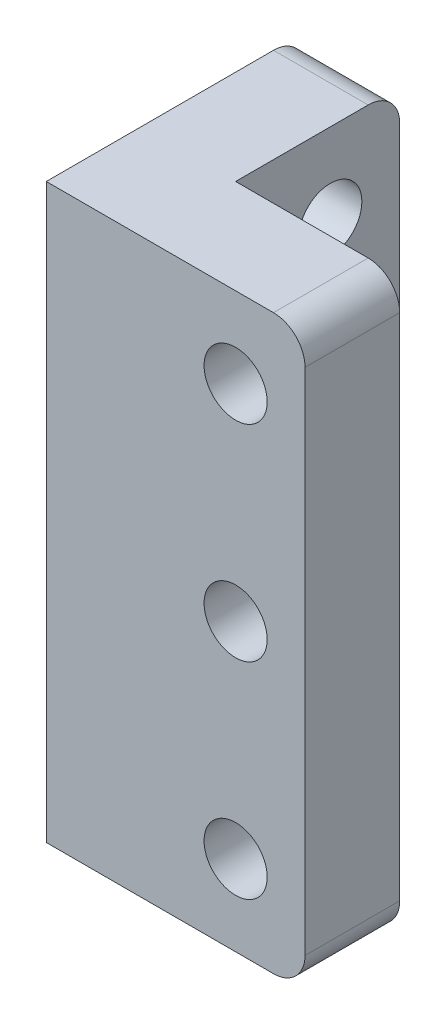
from build123d import *

# Parameters (mm, degrees)
BOSS_EXTRUDE1_DEPTH = 18.14
FILLET1_R           = 1
SKETCH3_R           = 1
CUT_EXTRUDE1_DEPTH  = 5.1
SKETCH4_R           = 1
CUT_EXTRUDE2_DEPTH  = 5.1
SKETCH5_R           = 1.7
CUT_EXTRUDE3_DEPTH  = 1.4
SKETCH6_R           = 1.7
CUT_EXTRUDE4_DEPTH  = 1.4
LPATTERN1_COUNT     = 2
LPATTERN1_PITCH     = 6.52
LPATTERN2_COUNT     = 2
LPATTERN2_PITCH     = 6.52


with BuildPart() as part:
    # Sketch1 → Boss-Extrude1 (new body)
    with BuildSketch(Plane(origin=(0, 0, 0), x_dir=(1, 0, 0), z_dir=(0, 1, 0))):
        Polygon((0, 0), (0, 5.2), (-3, 5.2), (-3, -3), (5.2, -3), (5.2, 0), align=None)
    extrude(amount=BOSS_EXTRUDE1_DEPTH)

    # Fillet1
    fillet1_edges = [part.edges().sort_by_distance(p)[0] for p in [
        (-1.5, 18.14, -5.2),
        (5.2, 18.14, 1.5),
        (5.2, 0, 1.5),
        (-1.5, 0, -5.2),
    ]]
    fillet(fillet1_edges, radius=FILLET1_R)

    # Sketch3 → Cut-Extrude1 (cut)
    with BuildSketch(Plane(origin=(0, 0, 0), x_dir=(0, 0, -1), z_dir=(1, 0, 0))):
        with Locations((3, 15.59)):
            Circle(SKETCH3_R)
    cut_extrude1 = extrude(amount=-CUT_EXTRUDE1_DEPTH, mode=Mode.SUBTRACT)

    # Sketch4 → Cut-Extrude2 (cut)
    with BuildSketch(Plane(origin=(0, 0, 0), x_dir=(-1, 0, 0), z_dir=(0, 0, -1))):
        with Locations((-3, 2.55)):
            Circle(SKETCH4_R)
    cut_extrude2 = extrude(amount=-CUT_EXTRUDE2_DEPTH, mode=Mode.SUBTRACT)

    # Sketch5 → Cut-Extrude3 (cut)
    with BuildSketch(Plane(origin=(0, 0, 0), x_dir=(-1, 0, 0), z_dir=(0, 0, -1))):
        with Locations((-3, 2.55)):
            Circle(SKETCH5_R)
    cut_extrude3 = extrude(amount=-CUT_EXTRUDE3_DEPTH, mode=Mode.SUBTRACT)

    # Sketch6 → Cut-Extrude4 (cut)
    with BuildSketch(Plane.ZY.offset(3)):
        with Locations((-3, 15.59)):
            Circle(SKETCH6_R)
    cut_extrude4 = extrude(amount=-CUT_EXTRUDE4_DEPTH, mode=Mode.SUBTRACT)

    # Mirror2: Cut-Extrude1, Cut-Extrude2, Cut-Extrude3, Cut-Extrude4 across plane
    add(cut_extrude1.mirror(Plane.ZX.offset(9.07)), mode=Mode.SUBTRACT)
    add(cut_extrude2.mirror(Plane.ZX.offset(9.07)), mode=Mode.SUBTRACT)
    add(cut_extrude3.mirror(Plane.ZX.offset(9.07)), mode=Mode.SUBTRACT)
    add(cut_extrude4.mirror(Plane.ZX.offset(9.07)), mode=Mode.SUBTRACT)

    # LPattern1: Cut-Extrude1, Cut-Extrude4 ×2
    with Locations(*[(0, -i * LPATTERN1_PITCH, 0) for i in range(1, LPATTERN1_COUNT)]):
        add(cut_extrude1, mode=Mode.SUBTRACT)
        add(cut_extrude4, mode=Mode.SUBTRACT)

    # LPattern2: Cut-Extrude2, Cut-Extrude3 ×2
    with Locations(*[(0, i * LPATTERN2_PITCH, 0) for i in range(1, LPATTERN2_COUNT)]):
        add(cut_extrude2, mode=Mode.SUBTRACT)
        add(cut_extrude3, mode=Mode.SUBTRACT)


solid = part.part
